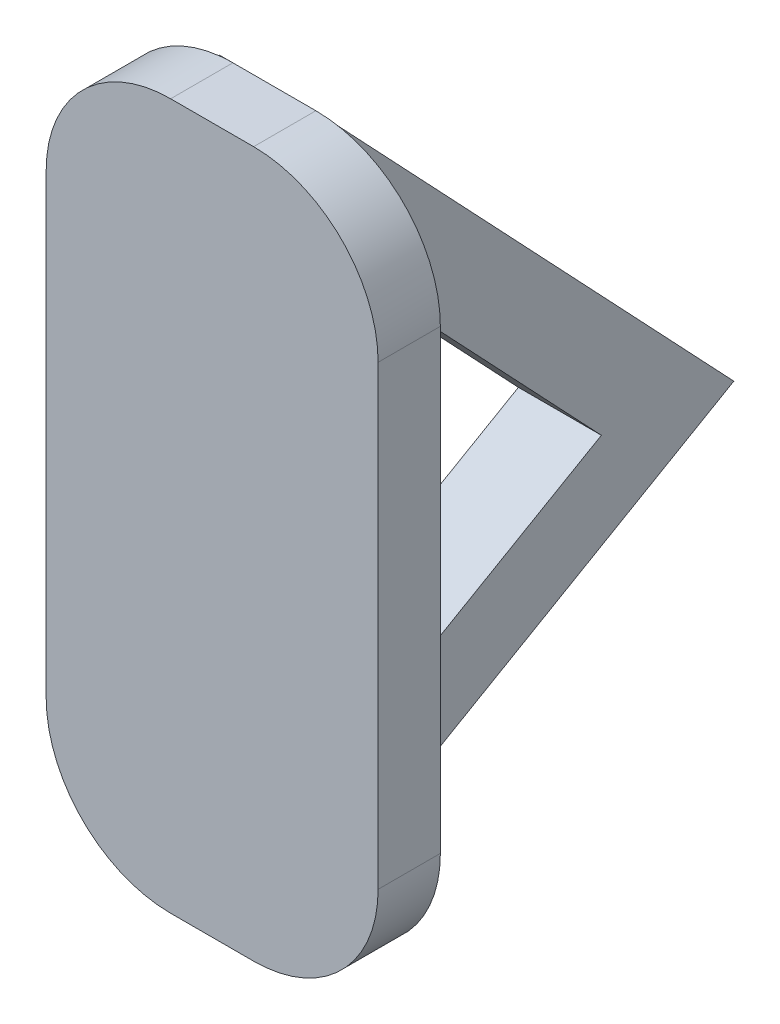
from build123d import *

# Parameters (mm, degrees)
BOSS_EXTRUDE1_DEPTH = 1.5
SKETCH3_W           = 2
SKETCH3_H           = 17
BOSS_EXTRUDE2_DEPTH = 20
CUT_EXTRUDE1_DEPTH  = 5.680224753
CUT_EXTRUDE2_DEPTH  = 5.680224753


with BuildPart() as part:
    # Sketch1 → Boss-Extrude1 (new body)
    with BuildSketch(Plane.XY):
        with BuildLine():
            Line((-1, 8.5), (1, 8.5))
            ThreePointArc((1, 8.5), (3.121320344, 7.621320344), (4, 5.5))
            Line((4, 5.5), (4, -5.5))
            ThreePointArc((4, -5.5), (3.121320344, -7.621320344), (1, -8.5))
            Line((1, -8.5), (-1, -8.5))
            ThreePointArc((-1, -8.5), (-3.121320344, -7.621320344), (-4, -5.5))
            Line((-4, -5.5), (-4, 5.5))
            ThreePointArc((-4, 5.5), (-3.121320344, 7.621320344), (-1, 8.5))
        make_face()
    extrude(amount=BOSS_EXTRUDE1_DEPTH)

    # Sketch3 → Boss-Extrude2 (add)
    with BuildSketch(Plane(origin=(0, 0, 0), x_dir=(-1, 0, 0), z_dir=(0, 0, -1))):
        with Locations((0.319775247, 0)):
            Rectangle(SKETCH3_W, SKETCH3_H)
    extrude(amount=BOSS_EXTRUDE2_DEPTH)

    # Sketch4 → Cut-Extrude1 (cut, through all)
    with BuildSketch(Plane(origin=(0.680224753, 0, 0), x_dir=(0, 0, -1), z_dir=(1, 0, 0))):
        Polygon((0, -8.5), (10.392304845, -2.5), (0, 8.5), (20, 8.5), (20, -8.5), align=None)
    extrude(amount=-CUT_EXTRUDE1_DEPTH, mode=Mode.SUBTRACT)

    # Sketch5 → Cut-Extrude2 (cut, through all)
    with BuildSketch(Plane(origin=(0.680224753, 0, 0), x_dir=(0, 0, -1), z_dir=(1, 0, 0))):
        Polygon((2, 3.470750697), (2, -5.035898385), (7.200217087, -2.03355165), align=None)
    extrude(amount=-CUT_EXTRUDE2_DEPTH, mode=Mode.SUBTRACT)


solid = part.part
